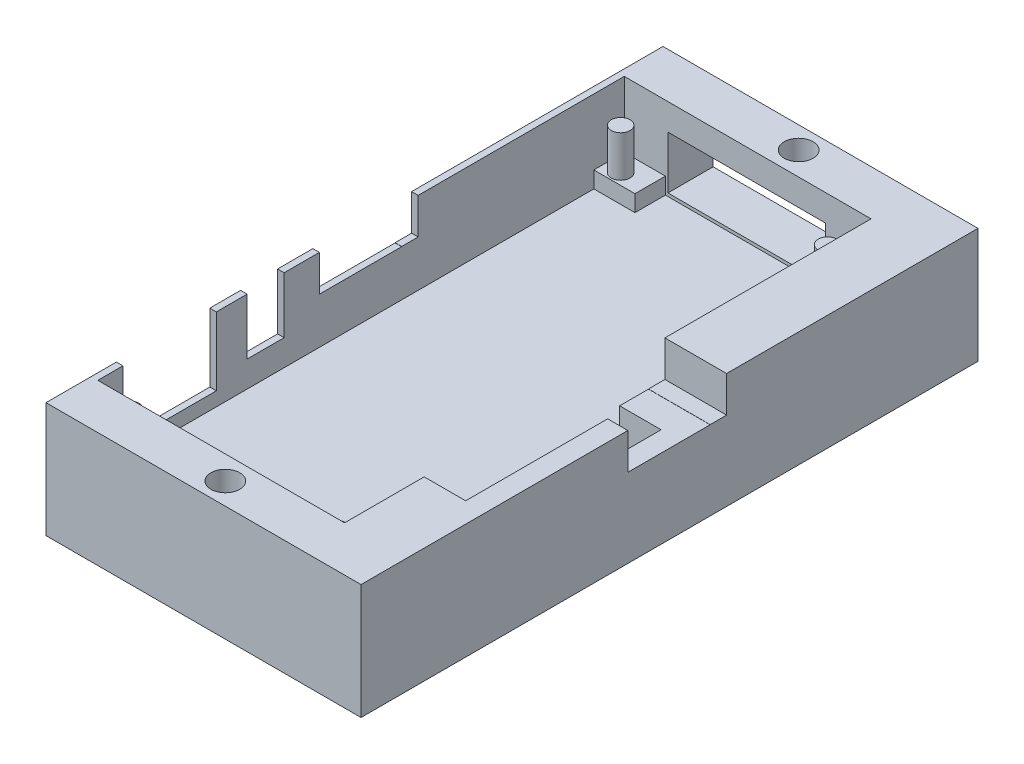
from build123d import *

# Parameters (mm, degrees)
CROQUIS1_W              = 45
CROQUIS1_H              = 75
SALIENTE_EXTRUIR1_DEPTH = 11
CROQUIS2_W              = 30
CROQUIS2_H              = 64
CORTAR_EXTRUIR1_DEPTH   = 7
CROQUIS3_W              = 5
CROQUIS3_H              = 3.7
SALIENTE_EXTRUIR2_DEPTH = 2
CROQUIS4_R              = 1.14
SALIENTE_EXTRUIR3_DEPTH = 5
CROQUIS8_W              = 5.042710394
CROQUIS8_H              = 23.757603043
CORTAR_EXTRUIR2_DEPTH   = 12
CROQUIS10_W             = 6.704370917
CROQUIS10_H             = 75
CORTAR_EXTRUIR3_DEPTH   = 18
CROQUIS11_W             = 11.359484983
CROQUIS11_H             = 5.310310124
CROQUIS11_W_2           = 4.5
CROQUIS11_H_2           = 3.836618742
CORTAR_EXTRUIR4_DEPTH   = 1
CROQUIS13_W             = 10
CROQUIS13_H             = 1.398702395
CROQUIS13_W_2           = 3.73
CROQUIS13_H_2           = 1.377461041
CORTAR_EXTRUIR5_DEPTH   = 38.3
CROQUIS15_R             = 1.75
CORTAR_EXTRUIR7_DEPTH   = 3
CROQUIS16_W             = 19.147118229
CROQUIS16_H             = 6.405137331
CORTAR_EXTRUIR8_DEPTH   = 10
CROQUIS17_W             = 0.795629083
CROQUIS17_H             = 4.286046827
CROQUIS17_H_2           = 3.741316105
SALIENTE_EXTRUIR4_DEPTH = 3
CROQUIS18_R             = 1.75
CORTAR_EXTRUIR9_DEPTH   = 3


with BuildPart() as part:
    # Croquis1 → Saliente-Extruir1 (new body)
    with BuildSketch(Plane(origin=(0, 0, 0), x_dir=(1, 0, 0), z_dir=(0, 1, 0))):
        Rectangle(CROQUIS1_W, CROQUIS1_H)
    extrude(amount=SALIENTE_EXTRUIR1_DEPTH)

    # Croquis2 → Cortar-Extruir1 (cut)
    with BuildSketch(Plane(origin=(0, 11, 0), x_dir=(1, 0, 0), z_dir=(0, 1, 0))):
        Rectangle(CROQUIS2_W, CROQUIS2_H)
    extrude(amount=-CORTAR_EXTRUIR1_DEPTH, mode=Mode.SUBTRACT)

    # Croquis3 → Saliente-Extruir2 (add)
    with BuildSketch(Plane(origin=(0, 4, 0), x_dir=(1, 0, 0), z_dir=(0, 1, 0))):
        with Locations((12.5, -30.15)):
            Rectangle(CROQUIS3_W, CROQUIS3_H)
        with Locations((-12.5, -30.15)):
            Rectangle(CROQUIS3_W, CROQUIS3_H)
        with Locations((12.5, 30.15)):
            Rectangle(CROQUIS3_W, CROQUIS3_H)
        with Locations((-12.5, 30.15)):
            Rectangle(CROQUIS3_W, CROQUIS3_H)
    extrude(amount=SALIENTE_EXTRUIR2_DEPTH)

    # Croquis4 → Saliente-Extruir3 (add)
    with BuildSketch(Plane(origin=(0, 6, 0), x_dir=(1, 0, 0), z_dir=(0, 1, 0))):
        with Locations((-13.085, -30.04)):
            Circle(CROQUIS4_R)
        with Locations((12.065, -30.04)):
            Circle(CROQUIS4_R)
        with Locations((-13.085, 29.65)):
            Circle(CROQUIS4_R)
        with Locations((12.065, 29.65)):
            Circle(CROQUIS4_R)
    extrude(amount=SALIENTE_EXTRUIR3_DEPTH)

    # Croquis8 → Cortar-Extruir2 (cut)
    with BuildSketch(Plane(origin=(0, 11, 0), x_dir=(1, 0, 0), z_dir=(0, 1, 0))):
        with Locations((17.521355197, -10.443778519)):
            Rectangle(CROQUIS8_W, CROQUIS8_H)
    extrude(amount=-CORTAR_EXTRUIR2_DEPTH, mode=Mode.SUBTRACT)

    # Croquis10 → Cortar-Extruir3 (cut)
    with BuildSketch(Plane(origin=(0, 11, 0), x_dir=(1, 0, 0), z_dir=(0, 1, 0))):
        with Locations((-19.147814542, 0)):
            Rectangle(CROQUIS10_W, CROQUIS10_H)
    extrude(amount=-CORTAR_EXTRUIR3_DEPTH, mode=Mode.SUBTRACT)

    # Croquis11 → Cortar-Extruir4 (cut)
    with BuildSketch(Plane.ZY.offset(15.795629083)):
        with Locations((23.268650218, 8.344844938)):
            Rectangle(CROQUIS11_W, CROQUIS11_H)
        with Locations((11.597591621, 9.081690629)):
            Rectangle(CROQUIS11_W_2, CROQUIS11_H_2)
    extrude(amount=-CORTAR_EXTRUIR4_DEPTH, mode=Mode.SUBTRACT)

    # Croquis13 → Cortar-Extruir5 (cut)
    with BuildSketch(Plane.ZY.offset(15.795629083)):
        with Locations((0.061544794, 10.300648802)):
            Rectangle(CROQUIS13_W, CROQUIS13_H)
        with Locations((-5.073455206, 10.311269479)):
            Rectangle(CROQUIS13_W_2, CROQUIS13_H_2)
    extrude(amount=-CORTAR_EXTRUIR5_DEPTH, mode=Mode.SUBTRACT)

    # Croquis15 → Cortar-Extruir7 (cut)
    with BuildSketch(Plane.XZ):
        with Locations((3.352185458, -34.85)):
            Circle(CROQUIS15_R)
        with Locations((3.352185458, 34.85)):
            Circle(CROQUIS15_R)
    extrude(amount=-CORTAR_EXTRUIR7_DEPTH, mode=Mode.SUBTRACT)

    # Croquis16 → Cortar-Extruir8 (cut)
    with BuildSketch(Plane(origin=(0, 0, -37.5), x_dir=(-1, 0, 0), z_dir=(0, 0, -1))):
        with Locations((0.122687914, 7.582003397)):
            Rectangle(CROQUIS16_W, CROQUIS16_H)
    extrude(amount=-CORTAR_EXTRUIR8_DEPTH, mode=Mode.SUBTRACT)

    # Croquis17 → Saliente-Extruir4 (add)
    with BuildSketch(Plane(origin=(0, 11, 0), x_dir=(1, 0, 0), z_dir=(0, 1, 0))):
        Polygon((-15.795629083, 6.938455206), (-15, 6.938455206), (-15, 32), (15, 32), (15, 6.938455206), (22.5, 6.938455206), (22.5, 37.5), (-15.795629083, 37.5), align=None)
        with Locations((-15.397814542, -7.204568208)):
            Rectangle(CROQUIS17_W, CROQUIS17_H)
        with Locations((-15.397814542, -15.718249674)):
            Rectangle(CROQUIS17_W, CROQUIS17_H_2)
        Polygon((22.5, -5.061544794), (20.042710394, -5.061544794), (20.042710394, -22.32258004), (15, -22.32258004), (15, -32), (-15, -32), (-15, -28.948392709), (-15.795629083, -28.948392709), (-15.795629083, -37.5), (22.5, -37.5), align=None)
    extrude(amount=SALIENTE_EXTRUIR4_DEPTH)

    # Croquis18 → Cortar-Extruir9 (cut)
    with BuildSketch(Plane(origin=(0, 14, 0), x_dir=(1, 0, 0), z_dir=(0, 1, 0))):
        with Locations((3.352185458, -34.85)):
            Circle(CROQUIS18_R)
        with Locations((3.352185458, 34.85)):
            Circle(CROQUIS18_R)
    extrude(amount=-CORTAR_EXTRUIR9_DEPTH, mode=Mode.SUBTRACT)


solid = part.part
